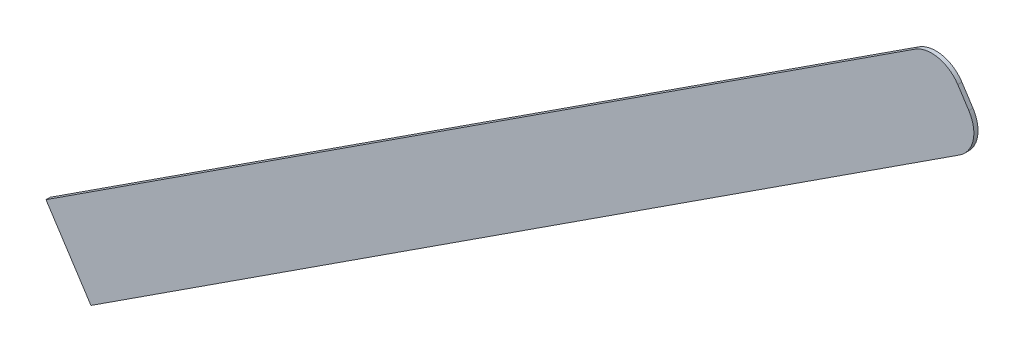
from build123d import *

# Parameters (mm, degrees)
BOSS_EXTRUDE1_DEPTH = 2


with BuildPart() as part:
    # Sketch2 → Boss-Extrude1 (new body)
    with BuildSketch(Plane.XY):
        with BuildLine():
            Line((-347.927779836, -207.150072061), (-326.237243483, -240.52012799))
            Line((-326.237243483, -240.52012799), (92.984564668, 31.974047308))
            ThreePointArc((92.984564668, 31.974047308), (99.483251285, 41.438138427), (97.386393653, 52.725526811))
            Line((97.386393653, 52.725526811), (92.045507817, 60.942274251))
            ThreePointArc((92.045507817, 60.942274251), (82.581416698, 67.440960868), (71.294028314, 65.344103236))
            Line((71.294028314, 65.344103236), (-347.927779836, -207.150072061))
        make_face()
    extrude(amount=BOSS_EXTRUDE1_DEPTH)


solid = part.part
